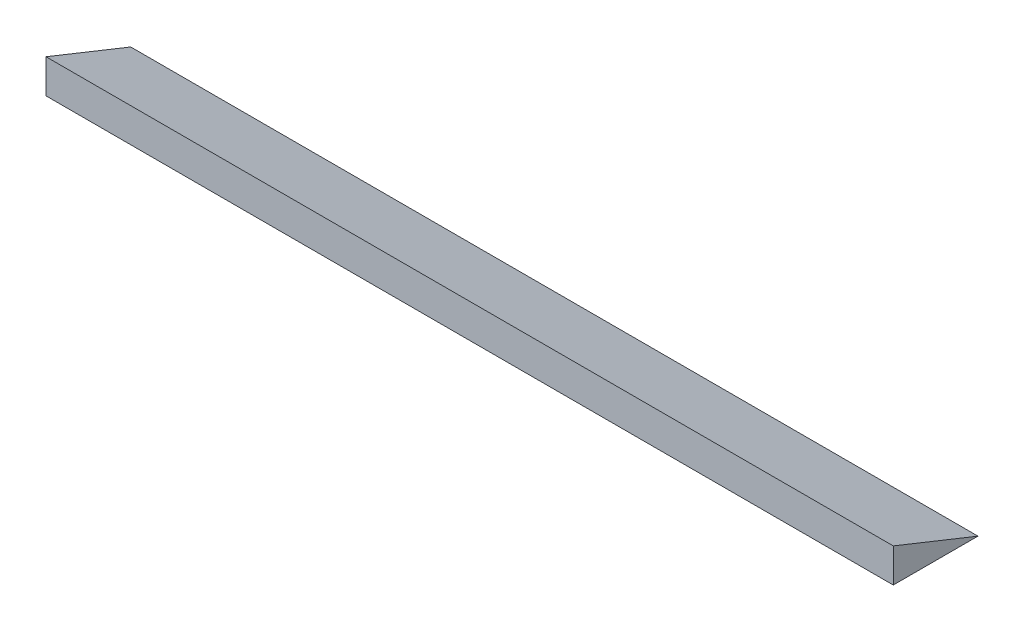
from build123d import *

# Parameters (mm, degrees)
BOSS_EXTRUDE1_DEPTH = 1000


with BuildPart() as part:
    # Sketch1 → Boss-Extrude1 (new body)
    with BuildSketch(Plane(origin=(0, 0, 0), x_dir=(0, 0, -1), z_dir=(1, 0, 0))):
        Polygon((0, 0), (100, 0), (0, 40), align=None)
    extrude(amount=BOSS_EXTRUDE1_DEPTH)


solid = part.part
